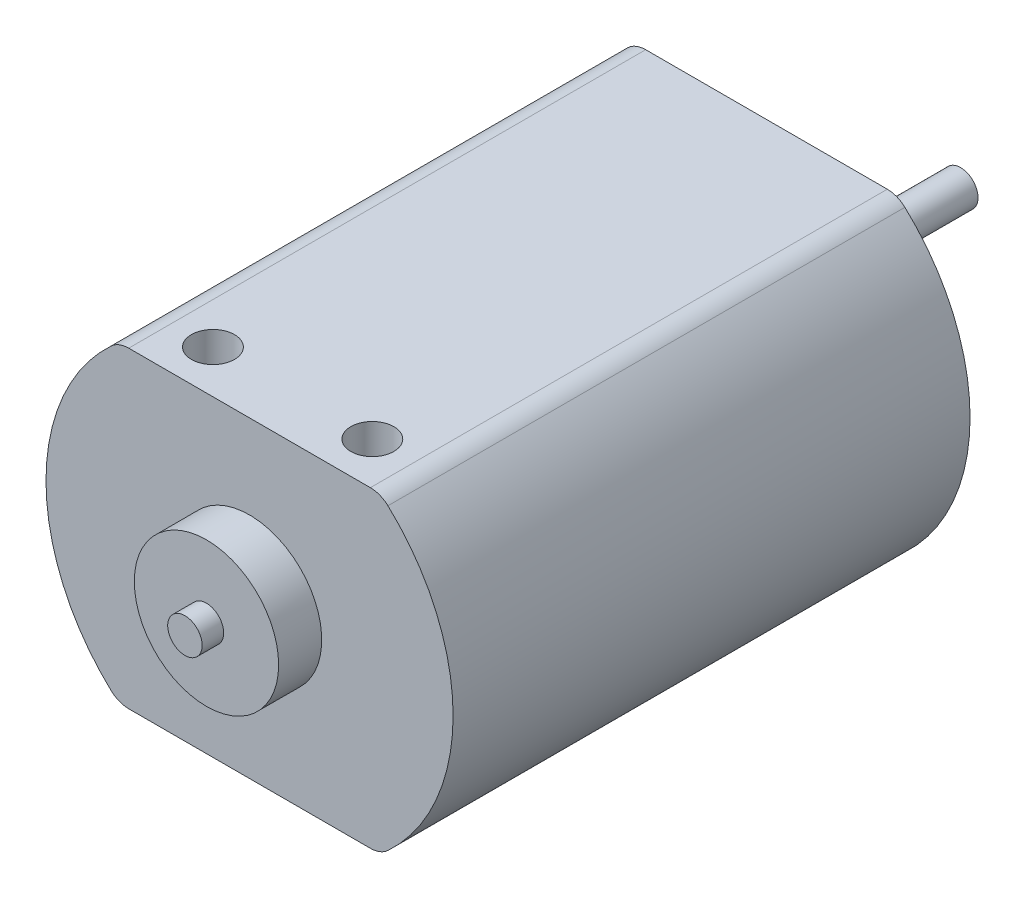
from build123d import *

# Parameters (mm, degrees)
BOSS_EXTRUDE1_DEPTH = 30.48
SKETCH2_R           = 4.2545
BOSS_EXTRUDE2_DEPTH = 2.54
SKETCH3_R           = 1.016
BOSS_EXTRUDE3_DEPTH = 1.27
SKETCH4_R           = 3.048
BOSS_EXTRUDE4_DEPTH = 1.5875
SKETCH5_R           = 1.0287
BOSS_EXTRUDE5_DEPTH = 9.8552
SKETCH6_R           = 1.27
CUT_EXTRUDE1_DEPTH  = 3.175


with BuildPart() as part:
    # Sketch1 → Boss-Extrude1 (new body)
    with BuildSketch(Plane.XY):
        with BuildLine():
            Line((-7.12333026, -9.2075), (7.12333026, -9.2075))
            ThreePointArc((7.12333026, -9.2075), (7.679816379, -9.102266788), (8.159451026, -8.8011))
            ThreePointArc((8.159451026, -8.8011), (12.0015, 0), (8.159451026, 8.8011))
            ThreePointArc((8.159451026, 8.8011), (7.679816379, 9.102266788), (7.12333026, 9.2075))
            Line((7.12333026, 9.2075), (-7.12333026, 9.2075))
            ThreePointArc((-7.12333026, 9.2075), (-7.679816379, 9.102266788), (-8.159451026, 8.8011))
            ThreePointArc((-8.159451026, 8.8011), (-12.0015, 0), (-8.159451026, -8.8011))
            ThreePointArc((-8.159451026, -8.8011), (-7.679816379, -9.102266788), (-7.12333026, -9.2075))
        make_face()
    extrude(amount=BOSS_EXTRUDE1_DEPTH)

    # Sketch2 → Boss-Extrude2 (add)
    with BuildSketch(Plane.XY.offset(30.48)):
        with Locations(Location((0, 0, 0), (0, 0, 180))):  # turned: the seam where the file's is
            Circle(SKETCH2_R)
    extrude(amount=BOSS_EXTRUDE2_DEPTH)

    # Sketch3 → Boss-Extrude3 (add)
    with BuildSketch(Plane.XY.offset(33.02)):
        Circle(SKETCH3_R)
    extrude(amount=BOSS_EXTRUDE3_DEPTH)

    # Sketch4 → Boss-Extrude4 (add)
    with BuildSketch(Plane(origin=(0, 0, 0), x_dir=(-1, 0, 0), z_dir=(0, 0, -1))):
        Circle(SKETCH4_R)
    extrude(amount=BOSS_EXTRUDE4_DEPTH)

    # Sketch5 → Boss-Extrude5 (add)
    with BuildSketch(Plane(origin=(0, 0, -1.5875), x_dir=(-1, 0, 0), z_dir=(0, 0, -1))):
        Circle(SKETCH5_R)
    extrude(amount=BOSS_EXTRUDE5_DEPTH)

    # Sketch6 → Cut-Extrude1 (cut)
    with BuildSketch(Plane(origin=(0, 9.2075, 0), x_dir=(1, 0, 0), z_dir=(0, 1, 0))):
        with Locations(Location((4.699, -27.94, 0), (0, 0, 270))):  # turned: the seam where the file's is
            Circle(SKETCH6_R)
        with Locations(Location((-4.699, -27.94, 0), (0, 0, 270))):  # turned: the seam where the file's is
            Circle(SKETCH6_R)
    extrude(amount=-CUT_EXTRUDE1_DEPTH, mode=Mode.SUBTRACT)


solid = part.part
